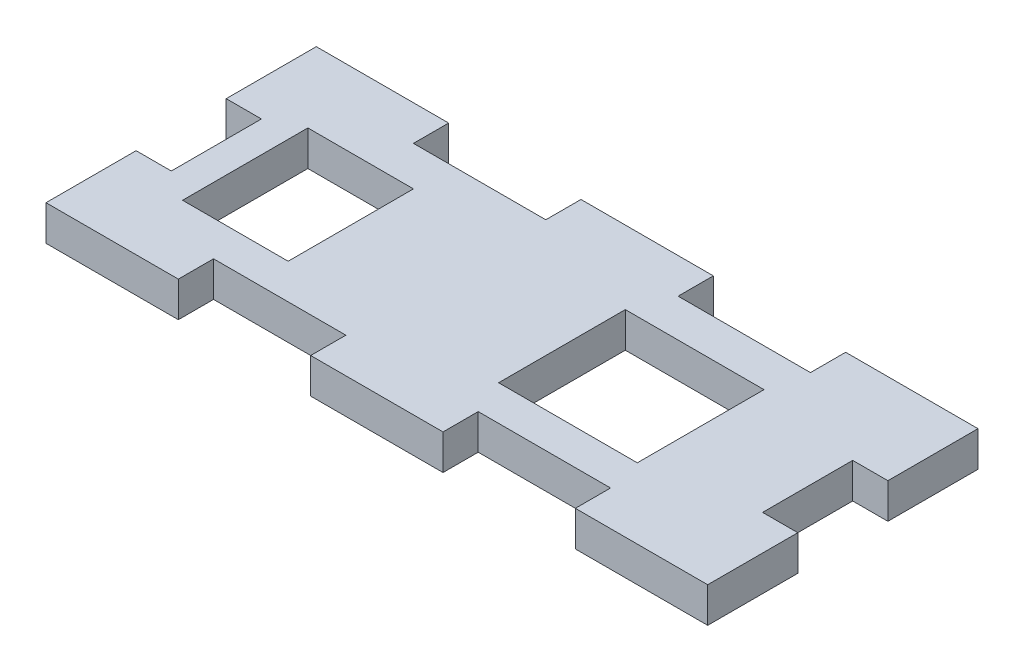
from build123d import *

# Parameters (mm, degrees)
SKETCH1_W           = 59.69
SKETCH1_H           = 24.384
BOSS_EXTRUDE2_DEPTH = 3.175
SKETCH3_W           = 11.938
SKETCH3_H           = 3.175
CUT_EXTRUDE2_DEPTH  = 3.175
LPATTERN2_COUNT     = 2
LPATTERN2_PITCH     = 23.876
SKETCH4_W           = 6.35
SKETCH4_H           = 8.128
CUT_EXTRUDE3_DEPTH  = 3.175
SKETCH5_W           = 9.525
SKETCH5_H           = 11.303
SKETCH5_W_2         = 12.5095
SKETCH5_H_2         = 11.43
CUT_EXTRUDE4_DEPTH  = 3.175


with BuildPart() as part:
    # Sketch1 → Boss-Extrude2 (new body)
    with BuildSketch(Plane(origin=(0, 0, 0), x_dir=(1, 0, 0), z_dir=(0, 1, 0))):
        Rectangle(SKETCH1_W, SKETCH1_H)
    extrude(amount=BOSS_EXTRUDE2_DEPTH)

    # Sketch3 → Cut-Extrude2 (cut)
    with BuildSketch(Plane(origin=(0, 3.175, 0), x_dir=(1, 0, 0), z_dir=(0, 1, 0))):
        with Locations((11.938, 10.6045)):
            Rectangle(SKETCH3_W, SKETCH3_H)
        with Locations((11.938, -10.6045)):
            Rectangle(SKETCH3_W, SKETCH3_H)
    cut_extrude2 = extrude(amount=-CUT_EXTRUDE2_DEPTH, mode=Mode.SUBTRACT)

    # LPattern2: Cut-Extrude2 ×2
    with Locations(*[(-i * LPATTERN2_PITCH, 0, 0) for i in range(1, LPATTERN2_COUNT)]):
        add(cut_extrude2, mode=Mode.SUBTRACT)

    # Sketch4 → Cut-Extrude3 (cut)
    with BuildSketch(Plane(origin=(0, 3.175, 0), x_dir=(1, 0, 0), z_dir=(0, 1, 0))):
        with Locations((-29.845, 0)):
            Rectangle(SKETCH4_W, SKETCH4_H)
        with Locations((29.845, 0)):
            Rectangle(SKETCH4_W, SKETCH4_H)
    extrude(amount=-CUT_EXTRUDE3_DEPTH, mode=Mode.SUBTRACT)

    # Sketch5 → Cut-Extrude4 (cut)
    with BuildSketch(Plane(origin=(0, 3.175, 0), x_dir=(1, 0, 0), z_dir=(0, 1, 0))):
        with Locations((-19.1135, -0.1905)):
            Rectangle(SKETCH5_W, SKETCH5_H)
        with Locations((10.89025, -0.127)):
            Rectangle(SKETCH5_W_2, SKETCH5_H_2)
    extrude(amount=-CUT_EXTRUDE4_DEPTH, mode=Mode.SUBTRACT)


solid = part.part
